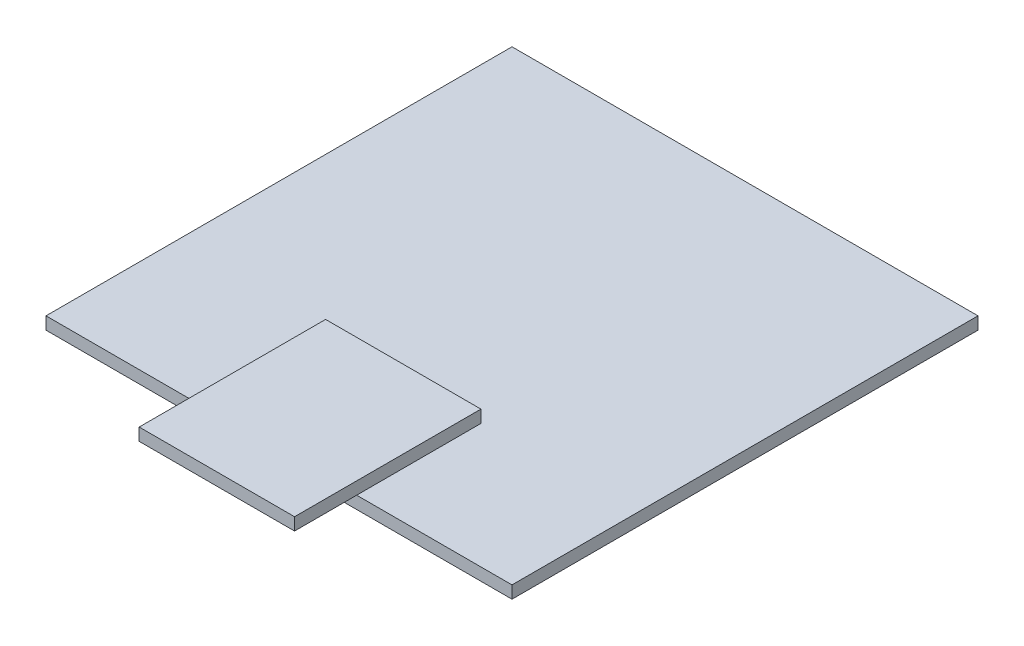
from build123d import *

# Parameters (mm, degrees)
SKETCH1_W           = 150
SKETCH1_H           = 150
BOSS_EXTRUDE1_DEPTH = 4
SKETCH2_W           = 50
SKETCH2_H           = 60
BOSS_EXTRUDE2_DEPTH = 4


with BuildPart() as part:
    # Sketch1 → Boss-Extrude1 (new body)
    with BuildSketch(Plane(origin=(0, 0, 0), x_dir=(1, 0, 0), z_dir=(0, 1, 0))):
        with Locations((75, 75)):
            Rectangle(SKETCH1_W, SKETCH1_H)
    extrude(amount=BOSS_EXTRUDE1_DEPTH)

    # Sketch2 → Boss-Extrude2 (add)
    with BuildSketch(Plane(origin=(0, 4, 0), x_dir=(1, 0, 0), z_dir=(0, 1, 0))):
        with Locations((75, 10)):
            Rectangle(SKETCH2_W, SKETCH2_H)
    extrude(amount=BOSS_EXTRUDE2_DEPTH)


solid = part.part
